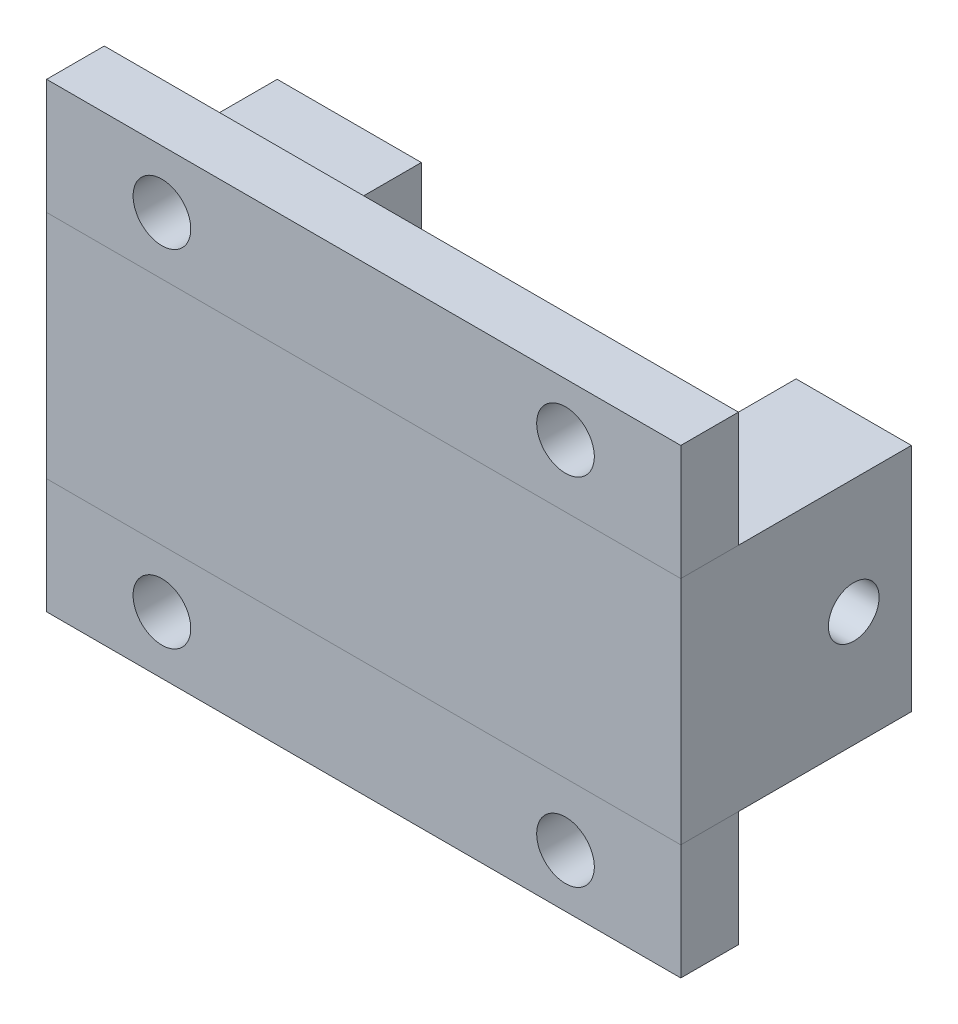
from build123d import *

# Parameters (mm, degrees)
SKETCH3_W                     = 110
SKETCH3_H                     = 40
BOSS_EXTRUDE2_DEPTH           = 20
SPLIT2_SURFACE_1_BACK         = 124.693
SPLIT2_SURFACE_1_DEPTH        = 249.386
SKETCH6_W                     = 110
SKETCH6_H                     = 10
BOSS_EXTRUDE3_DEPTH           = 20
SKETCH9_W                     = 5
SKETCH9_H                     = 10
M8_CLEARANCE_HOLE1_AT_2_COUNT = 2
M8_CLEARANCE_HOLE1_AT_2_PITCH = 70.004739842
SKETCH10_W                    = 65
SKETCH10_H                    = 20
CUT_EXTRUDE1_DEPTH            = 7
FILLET1_R                     = 5
SKETCH15_W                    = 4.4
SKETCH15_H                    = 20.001


with BuildPart() as part:
    # Sketch3 → Boss-Extrude2 (new, symmetric)
    with BuildSketch(Plane(origin=(0, 0, 0), x_dir=(1, 0, 0), z_dir=(0, 1, 0))):
        with Locations((55, 20)):
            Rectangle(SKETCH3_W, SKETCH3_H)
    extrude(amount=BOSS_EXTRUDE2_DEPTH, both=True)

    # Split2: cut with a surface, the side behind it stays
    # Split2 surface: a surface, the sketch's curves swept straight by 249.386 mm
    with BuildLine(Plane(origin=(0, 0, 0), x_dir=(1, 0, 0), z_dir=(0, 1, 0)).offset(-SPLIT2_SURFACE_1_BACK), mode=Mode.PRIVATE) as split2_surface_1_path:
        Line((25, 50.385249654), (25, 20))
        Line((25, 20), (90, 20))
        Line((90, 20), (90, 48.537928397))
    split2_surface_1 = Shell.extrude(split2_surface_1_path.wire(), (0 * SPLIT2_SURFACE_1_DEPTH, 1 * SPLIT2_SURFACE_1_DEPTH, 0 * SPLIT2_SURFACE_1_DEPTH))
    split(bisect_by=split2_surface_1, keep=Keep.BOTTOM)

    # Sketch10 → Cut-Extrude1 (cut)
    with BuildSketch(Plane(origin=(0, 0, -20), x_dir=(-1, 0, 0), z_dir=(0, 0, -1))):
        with Locations((-57.5, 0)):
            Rectangle(SKETCH10_W, SKETCH10_H)
    extrude(amount=-CUT_EXTRUDE1_DEPTH, mode=Mode.SUBTRACT)

    # Fillet1
    fillet1_edges = [part.edges().sort_by_distance(p)[0] for p in [
        (25, 10, -16.5),
        (25, -10, -16.5),
        (90, -10, -16.5),
        (90, 10, -16.5),
    ]]
    fillet(fillet1_edges, radius=FILLET1_R)

    # Sketch15 → M10x1.25 Tapped Hole1 (revolve, cut)
    with BuildSketch(Plane(origin=(110, 0, -30), x_dir=(0, 0, -1), z_dir=(0, 1, 0))):
        with Locations((2.2, 10.0005)):
            Rectangle(SKETCH15_W, SKETCH15_H)
    revolve(axis=Axis((116.35, 0, -30), (-1, 0, 0)), mode=Mode.SUBTRACT)


with BuildPart() as body_2:
    # Sketch6 → Boss-Extrude3 (new body)
    with BuildSketch(Plane(origin=(0, 20, 0), x_dir=(1, 0, 0), z_dir=(0, 1, 0))):
        with Locations((55, 5)):
            Rectangle(SKETCH6_W, SKETCH6_H)
    extrude(amount=BOSS_EXTRUDE3_DEPTH)

    # Sketch9 → M8 Clearance Hole1 (revolve, cut)
    with BuildSketch(Plane(origin=(20, 30, -10), x_dir=(0, 1, 0), z_dir=(1, 0, 0))):
        with Locations((2.5, 5)):
            Rectangle(SKETCH9_W, SKETCH9_H)
    m8_clearance_hole1 = revolve(axis=Axis((20, 30, -16.35), (0, 0, 1)), mode=Mode.SUBTRACT)

    # M8 Clearance Hole1 at 2: M8 Clearance Hole1 ×2
    with Locations(*[Vector(0.9999322925508326, 0.01163659374714847, 0) * (i * M8_CLEARANCE_HOLE1_AT_2_PITCH) for i in range(1, M8_CLEARANCE_HOLE1_AT_2_COUNT)]):
        add(m8_clearance_hole1, mode=Mode.SUBTRACT)


with BuildPart() as body_3:
    # Mirror1: mirrored copy
    add(body_2.part.mirror(Plane.ZX))


solid = Compound([part.part, body_2.part, body_3.part])
